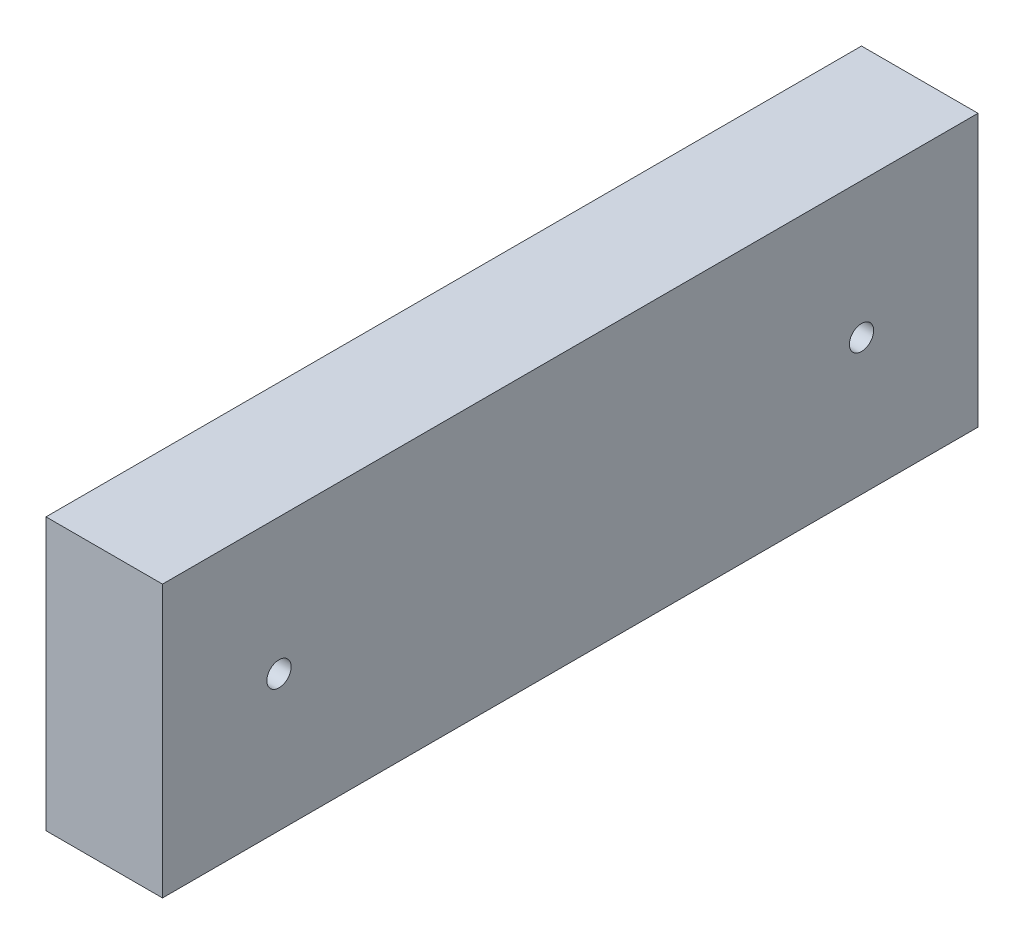
from build123d import *

# Parameters (mm, degrees)
SKETCH1_W                      = 38.1
SKETCH1_H                      = 88.9
BOSS_EXTRUDE1_DEPTH            = 266.7
F_5_16_0_3125_DIAMETER_HOLE1_D = 7.9375


with BuildPart() as part:
    # Sketch1 → Boss-Extrude1 (new body)
    with BuildSketch(Plane.XY):
        Rectangle(SKETCH1_W, SKETCH1_H)
    extrude(amount=BOSS_EXTRUDE1_DEPTH)

    # 5/16 (0.3125) Diameter Hole1 (through all)
    with Locations(Plane(origin=(19.05, 0, 0), x_dir=(0, 0, -1), z_dir=(1, 0, 0))):
        with Locations((-228.6, 0), (-38.1, 0)):
            Hole(F_5_16_0_3125_DIAMETER_HOLE1_D / 2)


solid = part.part
